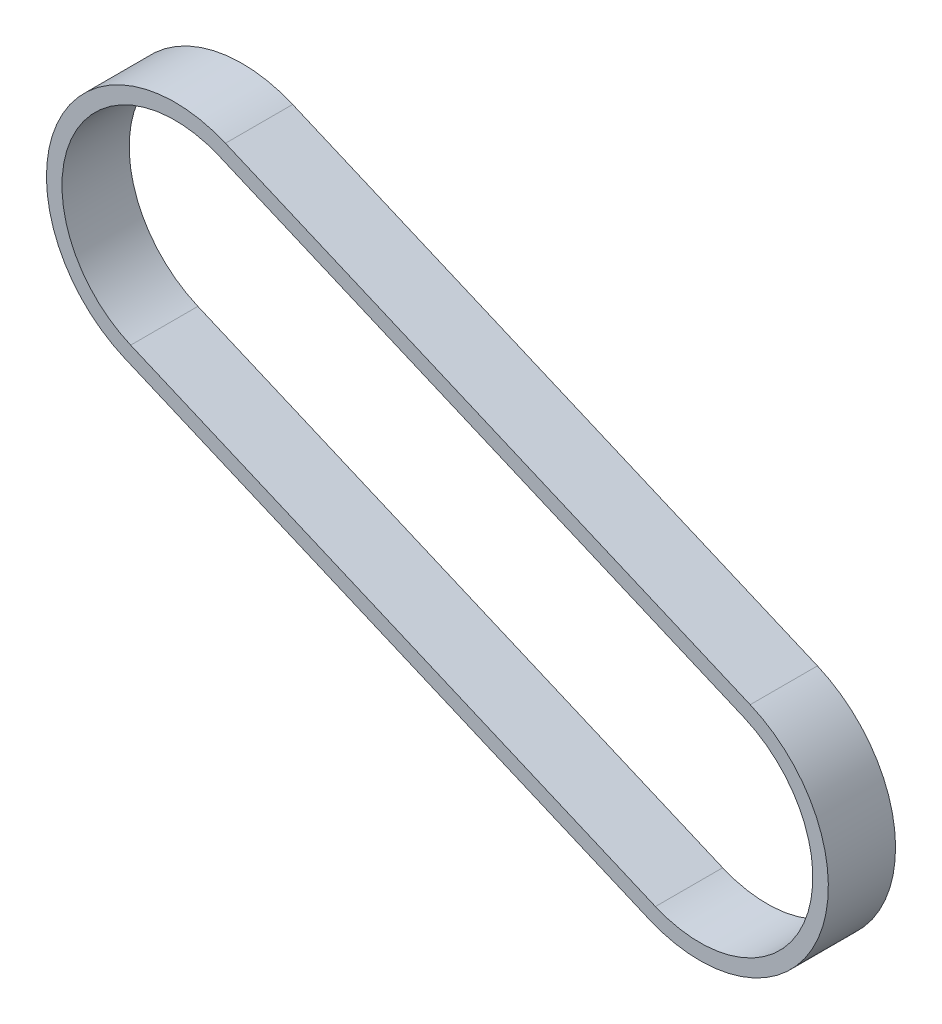
from build123d import *

# Parameters (mm, degrees)
EXTRUDE_THIN1_DEPTH = 11


with BuildPart() as part:
    # Sketch2 → Extrude-Thin1 (new body)
    with BuildSketch(Plane.XY):
        with BuildLine():
            Line((-77.955928658, 56.877181426), (7.931763202, 20.247696874))
            ThreePointArc((7.931763202, 20.247696874), (19.031318392, -7.359604237), (-8.575982719, -18.459159426))
            Line((-8.575982719, -18.459159426), (-94.463674578, 18.170325126))
            ThreePointArc((-94.463674578, 18.170325126), (-105.563229768, 45.777626236), (-77.955928658, 56.877181426))
        make_face()
        with BuildLine():
            Line((-78.952356287, 54.540788484), (6.935335573, 17.911303931))
            ThreePointArc((6.935335573, 17.911303931), (16.69492545, -6.363176607), (-7.579555089, -16.122766484))
            Line((-7.579555089, -16.122766484), (-93.467246949, 20.506718068))
            ThreePointArc((-93.467246949, 20.506718068), (-103.226836826, 44.781198606), (-78.952356287, 54.540788484))
        make_face(mode=Mode.SUBTRACT)
    extrude(amount=-EXTRUDE_THIN1_DEPTH)


solid = part.part
